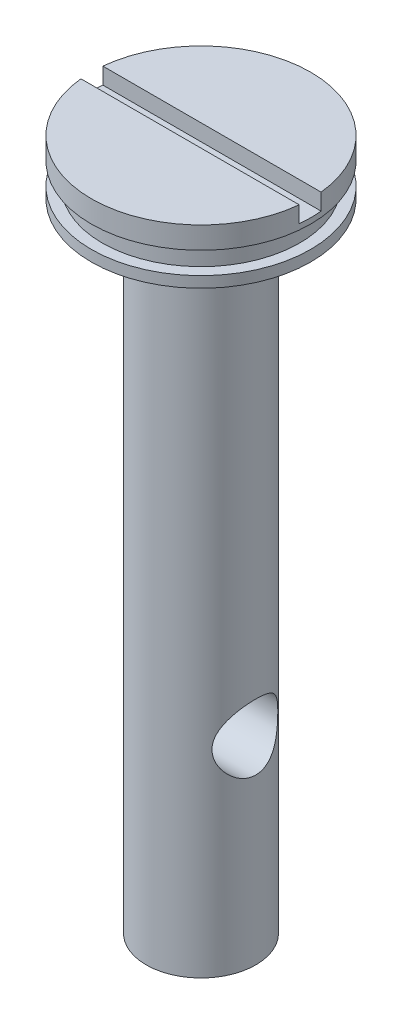
from build123d import *

# Parameters (mm, degrees)
SKIZZE5_W                            = 2
SKIZZE5_H                            = 1.5
SCHNITT_LINEAR_AUSTRAGEN1_DEPTH      = 11
SCHNITT_LINEAR_AUSTRAGEN1_DEPTH_BACK = 11
F_6_0_6_DURCHMESSER_BOHRUNG1_D       = 6


with BuildPart() as part:
    # Skizze1 → Rotation1 (revolve)
    with BuildSketch(Plane(origin=(0, 0, 0), x_dir=(0, 0, -1), z_dir=(1, 0, 0)), mode=Mode.PRIVATE) as rotation1_sk:
        Polygon((10, 43), (10, 45), (0, 45), (0, -18), (5, -18), (5, 40), (10, 40), (10, 41), (9, 41), (9, 43), align=None)
    revolve(rotation1_sk.sketch.rotate(Axis((0, -18, 0), (0, -1, 0)), 180), axis=Axis((0, -18, 0), (0, -1, 0)))  # turned: the seam where the file's is

    # Skizze5 → Schnitt-Linear austragen1 (cut, two sides)
    with BuildSketch(Plane(origin=(0, 0, 0), x_dir=(0, 0, -1), z_dir=(1, 0, 0))) as schnitt_linear_austragen1_sk:
        with Locations((0, 44.25)):
            Rectangle(SKIZZE5_W, SKIZZE5_H)
    extrude(amount=SCHNITT_LINEAR_AUSTRAGEN1_DEPTH, mode=Mode.SUBTRACT)
    extrude(schnitt_linear_austragen1_sk.sketch, amount=-SCHNITT_LINEAR_AUSTRAGEN1_DEPTH_BACK, mode=Mode.SUBTRACT)

    # Ø6.0 (6) Durchmesser Bohrung1 (through all)
    with Locations(Plane(origin=(5, 0, 0), x_dir=(0, 0, 1), z_dir=(1, 0, 0))):
        with Locations((0, 0)):
            Hole(F_6_0_6_DURCHMESSER_BOHRUNG1_D / 2)


solid = part.part
